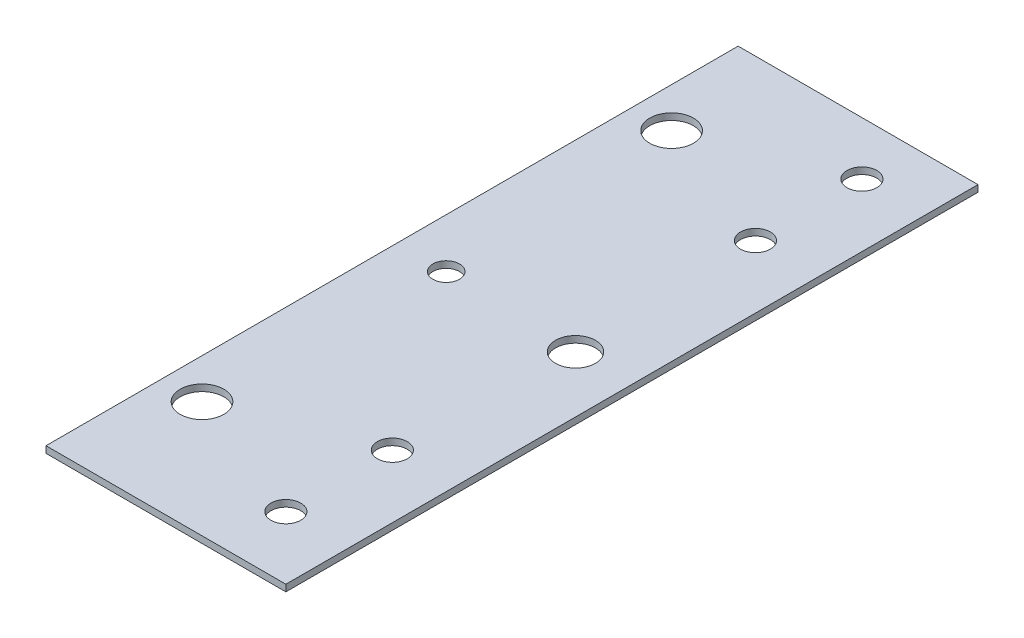
from build123d import *

# Parameters (mm, degrees)
SKETCH1_R           = 5.207
SKETCH1_R_2         = 3.556
BOSS_EXTRUDE1_DEPTH = 1.5875
SKETCH2_R           = 3.175
CUT_EXTRUDE1_DEPTH  = 2.5875
SKETCH3_R           = 4.7625
CUT_EXTRUDE2_DEPTH  = 2.54


with BuildPart() as part:
    # Sketch1 → Boss-Extrude1 (new body)
    with BuildSketch(Plane(origin=(0, 0, 0), x_dir=(1, 0, 0), z_dir=(0, 1, 0))):
        Polygon((-28.60675, 81.407), (28.60675, 81.407), (28.60675, -81.407), (28.60675, -83.693), (-28.60675, -83.693), (-28.60675, -81.407), align=None)
        with Locations((-19.08175, 56.007)):
            Circle(SKETCH1_R, mode=Mode.SUBTRACT)
        with Locations((-19.08175, -56.007)):
            Circle(SKETCH1_R, mode=Mode.SUBTRACT)
        with Locations((13.62075, 68.707)):
            Circle(SKETCH1_R_2, mode=Mode.SUBTRACT)
        with Locations((13.62075, 43.307)):
            Circle(SKETCH1_R_2, mode=Mode.SUBTRACT)
        with Locations((13.62075, -43.307)):
            Circle(SKETCH1_R_2, mode=Mode.SUBTRACT)
        with Locations((13.62075, -68.707)):
            Circle(SKETCH1_R_2, mode=Mode.SUBTRACT)
    extrude(amount=BOSS_EXTRUDE1_DEPTH)

    # Sketch2 → Cut-Extrude1 (cut, through all)
    with BuildSketch(Plane(origin=(0, 1.5875, 0), x_dir=(1, 0, 0), z_dir=(0, 1, 0))):
        with Locations((-16.849815709, 0.01058698)):
            Circle(SKETCH2_R)
    extrude(amount=-CUT_EXTRUDE1_DEPTH, mode=Mode.SUBTRACT)

    # Sketch3 → Cut-Extrude2 (cut)
    with BuildSketch(Plane(origin=(0, 1.5875, 0), x_dir=(1, 0, 0), z_dir=(0, 1, 0))):
        with Locations((15.14475, -1.143)):
            Circle(SKETCH3_R)
    extrude(amount=-CUT_EXTRUDE2_DEPTH, mode=Mode.SUBTRACT)


solid = part.part
